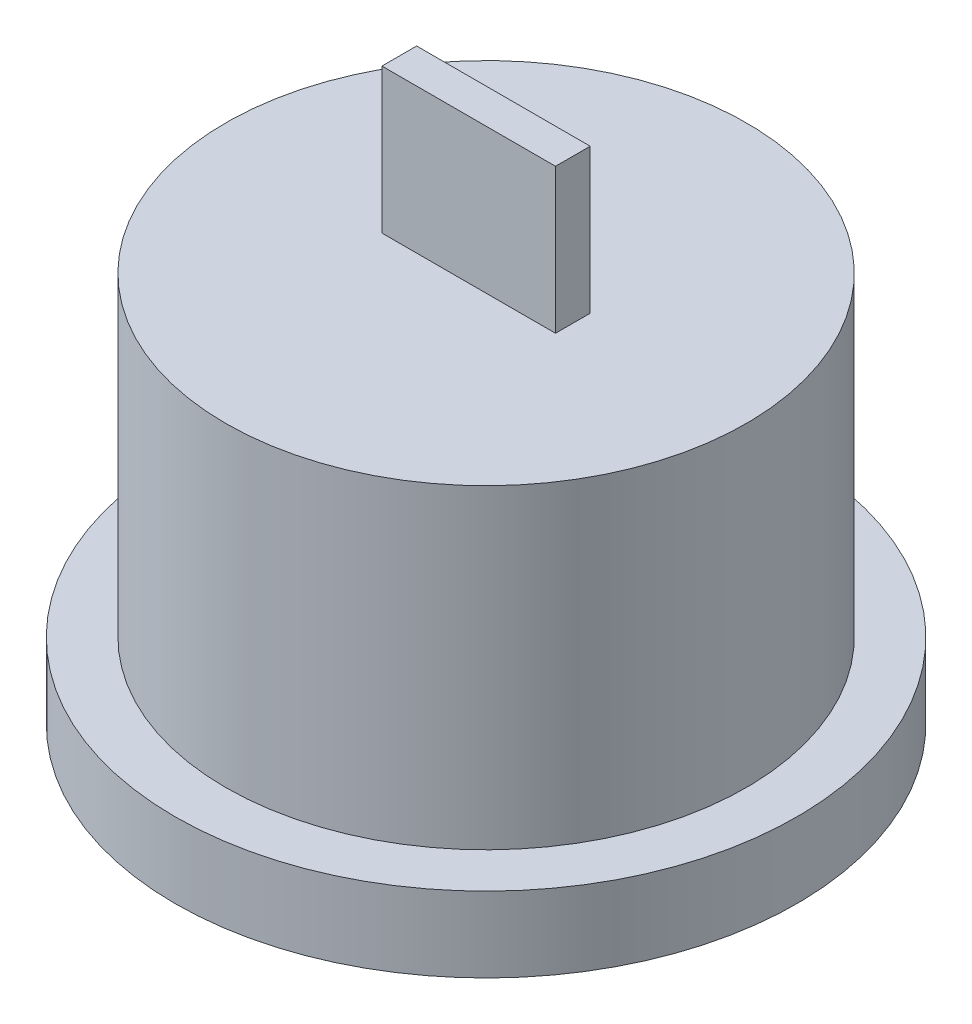
from build123d import *

# Parameters (mm, degrees)
SKETCH1_R           = 10.75
BOSS_EXTRUDE1_DEPTH = 2.6
SKETCH2_R           = 9
BOSS_EXTRUDE2_DEPTH = 10.9
SKETCH3_W           = 6
SKETCH3_H           = 1.2
BOSS_EXTRUDE3_DEPTH = 5
SKETCH4_R           = 9
CUT_EXTRUDE2_DEPTH  = 2
CUT_EXTRUDE3_DEPTH  = 5


with BuildPart() as part:
    # Sketch1 → Boss-Extrude1 (new body)
    with BuildSketch(Plane(origin=(0, 0, 0), x_dir=(1, 0, 0), z_dir=(0, 1, 0))):
        Circle(SKETCH1_R)
    extrude(amount=BOSS_EXTRUDE1_DEPTH)

    # Sketch2 → Boss-Extrude2 (add)
    with BuildSketch(Plane(origin=(0, 2.6, 0), x_dir=(1, 0, 0), z_dir=(0, 1, 0))):
        Circle(SKETCH2_R)
    extrude(amount=BOSS_EXTRUDE2_DEPTH)

    # Sketch3 → Boss-Extrude3 (add)
    with BuildSketch(Plane(origin=(0, 13.5, 0), x_dir=(1, 0, 0), z_dir=(0, 1, 0))):
        Rectangle(SKETCH3_W, SKETCH3_H)
    extrude(amount=BOSS_EXTRUDE3_DEPTH)

    # Sketch4 → Cut-Extrude2 (cut)
    with BuildSketch(Plane.XZ):
        Circle(SKETCH4_R)
    extrude(amount=-CUT_EXTRUDE2_DEPTH, mode=Mode.SUBTRACT)

    # Sketch5 → Cut-Extrude3 (cut)
    with BuildSketch(Plane.XZ.offset(-2)):
        Polygon((-3, 0.9), (-3, -0.2), (-2.3, -0.9), (2.3, -0.9), (3, -0.2), (3, 0.9), align=None)
    extrude(amount=-CUT_EXTRUDE3_DEPTH, mode=Mode.SUBTRACT)


solid = part.part
